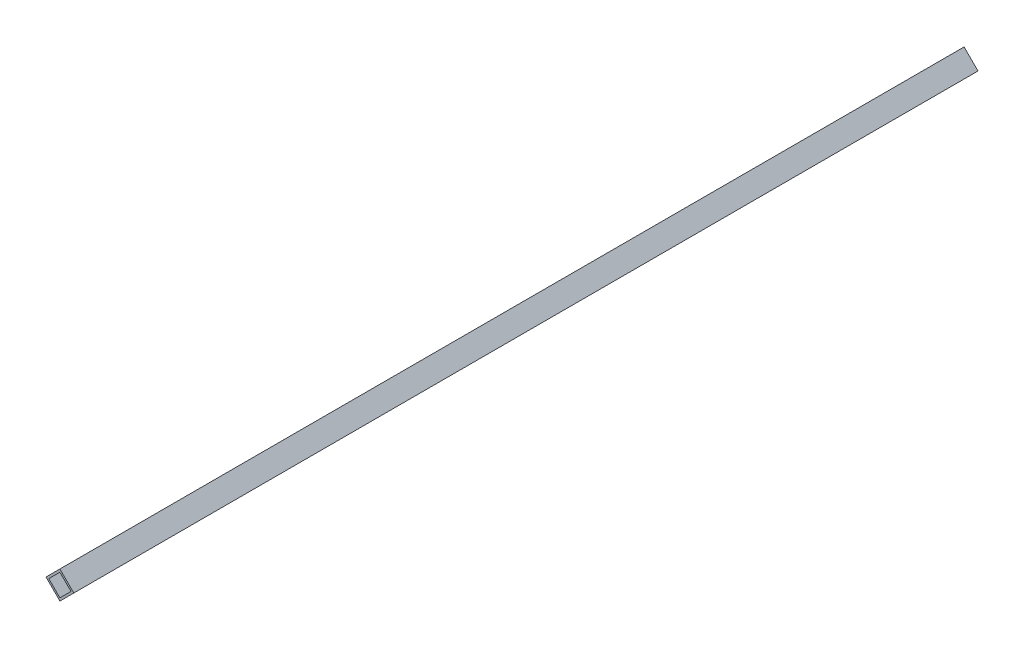
from build123d import *

# Parameters (mm, degrees)
EXTRUDE_THIN1_DEPTH = 230


with BuildPart() as part:
    # Sketch1 → Extrude-Thin1 (new, symmetric)
    with BuildSketch(Plane.XY):
        Polygon((0, -7.071067812), (7.071067812, 0), (0, 7.071067812), (-7.071067812, 0), align=None)
        Polygon((0, -5.656854249), (5.656854249, 0), (0, 5.656854249), (-5.656854249, 0), align=None, mode=Mode.SUBTRACT)
    extrude(amount=EXTRUDE_THIN1_DEPTH, both=True)


solid = part.part
